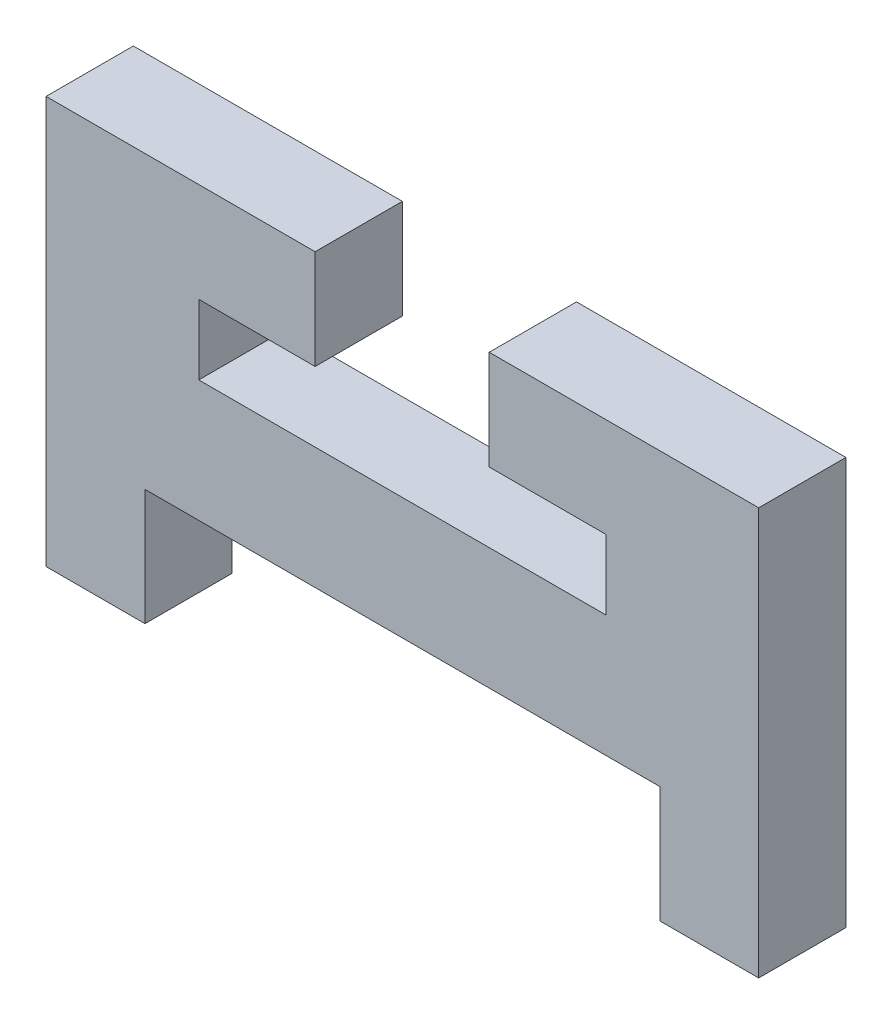
from build123d import *

# Parameters (mm, degrees)
SALIENTE_EXTRUIR1_DEPTH = 3


with BuildPart() as part:
    # Model → Saliente-Extruir1 (new body)
    with BuildSketch(Plane.XY):
        Polygon((46.92, 30.082683294), (39.42, 30.082683294), (39.42, 32.482683294), (43.42, 32.482683294), (43.42, 35.9), (34.17, 35.9), (34.17, 21.9), (37.57, 21.9), (37.57, 25.9), (55.27, 25.9), (55.27, 21.9), (58.67, 21.9), (58.67, 35.9), (49.406385402, 35.9), (49.406385402, 32.482683294), (53.42, 32.482683294), (53.42, 30.082683294), align=None)
    extrude(amount=SALIENTE_EXTRUIR1_DEPTH)


solid = part.part
